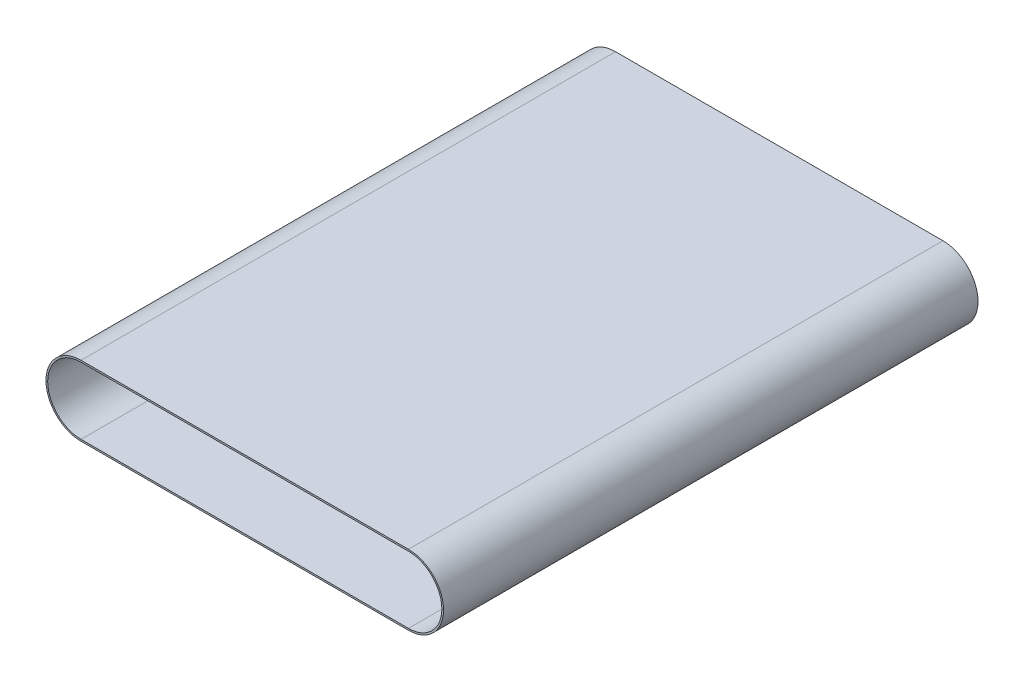
from build123d import *

# Parameters (mm, degrees)
SALIENTE_EXTRUIR2_DEPTH = 400


with BuildPart() as part:
    # Croquis1 → Saliente-Extruir2 (new body)
    with BuildSketch(Plane.XY):
        with BuildLine():
            Line((-122.5, 26.25), (122.5, 26.25))
            ThreePointArc((122.5, 26.25), (148.75, 0), (122.5, -26.25))
            Line((122.5, -26.25), (-122.5, -26.25))
            ThreePointArc((-122.5, -26.25), (-148.75, 0), (-122.5, 26.25))
        make_face()
        with BuildLine():
            Line((-122.5, 25), (122.5, 25))
            ThreePointArc((122.5, 25), (147.5, 0), (122.5, -25))
            Line((122.5, -25), (-122.5, -25))
            ThreePointArc((-122.5, -25), (-147.5, 0), (-122.5, 25))
        make_face(mode=Mode.SUBTRACT)
    extrude(amount=SALIENTE_EXTRUIR2_DEPTH)


solid = part.part
